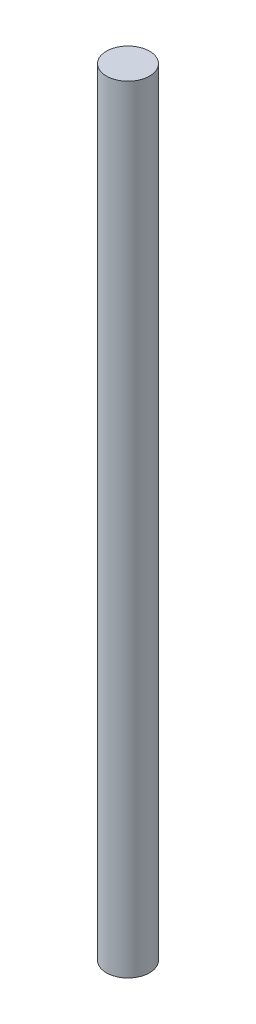
from build123d import *

# Parameters (mm, degrees)
SKETCH1_R           = 6.35
BOSS_EXTRUDE1_DEPTH = 228.6


with BuildPart() as part:
    # Sketch1 → Boss-Extrude1 (new body)
    with BuildSketch(Plane(origin=(0, 0, 0), x_dir=(1, 0, 0), z_dir=(0, 1, 0))):
        Circle(SKETCH1_R)
    extrude(amount=BOSS_EXTRUDE1_DEPTH)


solid = part.part
